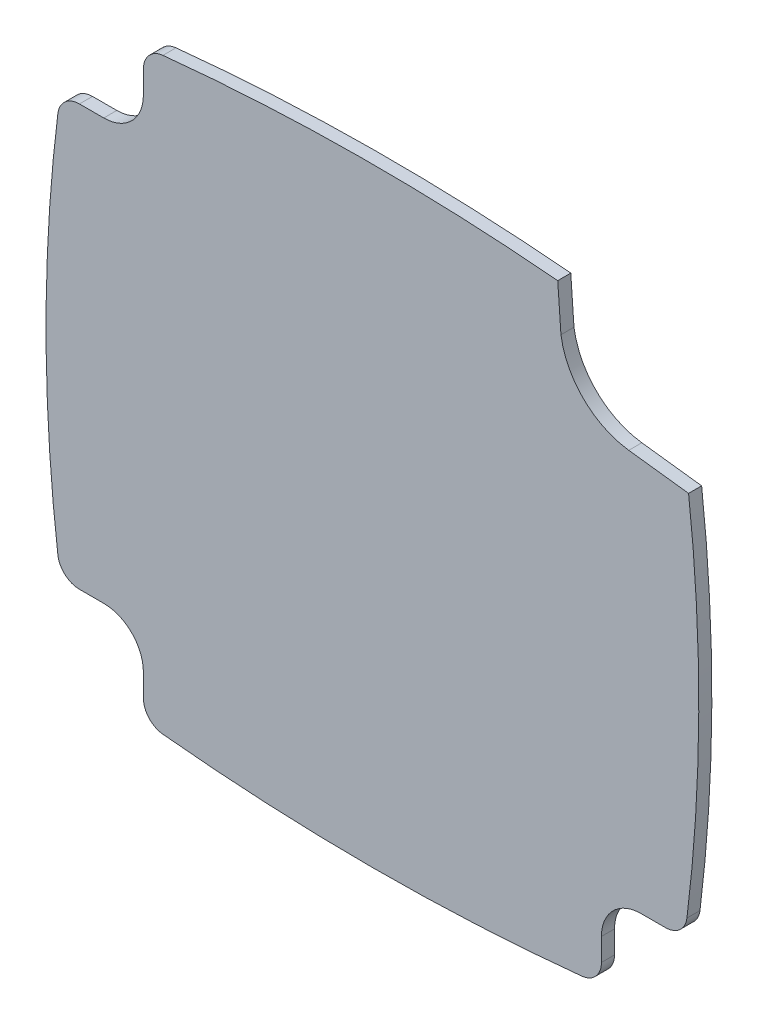
from build123d import *

# Parameters (mm, degrees)
Y_KSEKLIK_EKSTR_ZYON1_DEPTH = 0.6


with BuildPart() as part:
    # Çizim1 → Yükseklik-Ekstrüzyon1 (new body)
    with BuildSketch(Plane.XY):
        with BuildLine():
            Line((-13.469525999, 9.663203574), (-12.350808448, 9.663203574))
            ThreePointArc((-12.350808448, 9.663203574), (-11.063665594, 10.196355601), (-10.530513567, 11.483498455))
            Line((-10.530513567, 11.483498455), (-10.530513567, 12.521258908))
            ThreePointArc((-10.530513567, 12.521258908), (-10.272569175, 13.191597237), (-9.631806617, 13.51611554))
            ThreePointArc((-9.631806617, 13.51611554), (-0.558041692, 14.00355333), (8.520819322, 13.622648864))
            Line((8.520819322, 13.622648864), (8.667659763, 11.541275042))
            ThreePointArc((8.667659763, 11.541275042), (9.715042524, 9.495679657), (11.786557422, 8.500542906))
            Line((11.786557422, 8.500542906), (14.536783397, 8.160642995))
            ThreePointArc((14.536783397, 8.160642995), (15.004494724, -0.315108806), (14.461908683, -8.786396952))
            ThreePointArc((14.461908683, -8.786396952), (14.131646314, -9.412601125), (13.469525999, -9.663203574))
            Line((13.469525999, -9.663203574), (12.350808448, -9.663203574))
            ThreePointArc((12.350808448, -9.663203574), (11.063665594, -10.196355601), (10.530513567, -11.483498455))
            Line((10.530513567, -11.483498455), (10.530513567, -12.521258908))
            ThreePointArc((10.530513567, -12.521258908), (10.272569175, -13.191597237), (9.631806617, -13.51611554))
            ThreePointArc((9.631806617, -13.51611554), (0, -14.005190821), (-9.631806617, -13.51611554))
            ThreePointArc((-9.631806617, -13.51611554), (-10.272569175, -13.191597237), (-10.530513567, -12.521258908))
            Line((-10.530513567, -12.521258908), (-10.530513567, -11.483498455))
            ThreePointArc((-10.530513567, -11.483498455), (-11.063665594, -10.196355601), (-12.350808448, -9.663203574))
            Line((-12.350808448, -9.663203574), (-13.469525999, -9.663203574))
            ThreePointArc((-13.469525999, -9.663203574), (-14.131646314, -9.412601125), (-14.461908683, -8.786396952))
            ThreePointArc((-14.461908683, -8.786396952), (-15.005190821, 0), (-14.461908683, 8.786396952))
            ThreePointArc((-14.461908683, 8.786396952), (-14.131646314, 9.412601125), (-13.469525999, 9.663203574))
        make_face()
    extrude(amount=Y_KSEKLIK_EKSTR_ZYON1_DEPTH)


solid = part.part
